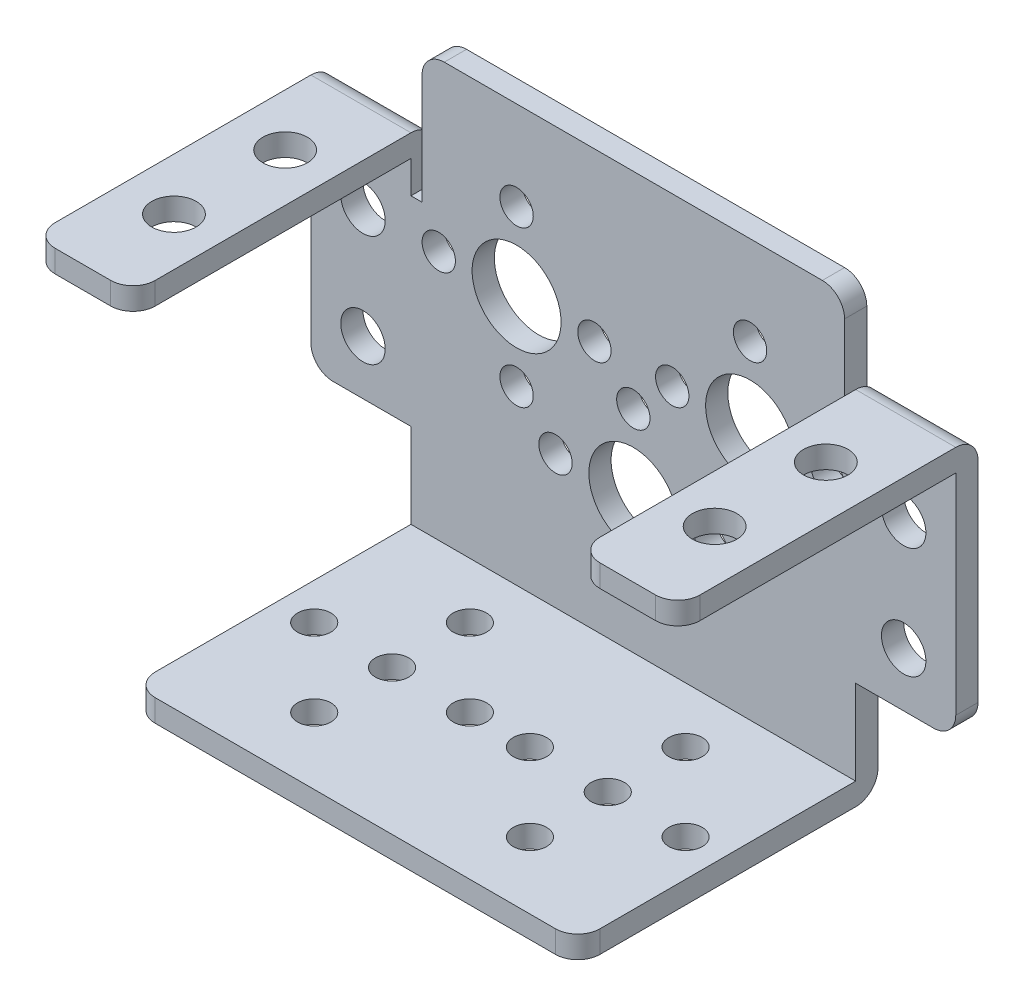
from build123d import *

# Parameters (mm, degrees)
SKETCH_1_R      = 4
SKETCH_1_R_2    = 1.5
SKETCH_1_R_3    = 2
EXTRUDE_1_DEPTH = 2
SKETCH_2_R      = 1.5
EXTRUDE_2_DEPTH = 2
FILLET_2_R      = 2
SKETCH_3_R      = 2
EXTRUDE_3_DEPTH = 2
FILLET_3_R      = 2
FILLET_4_R      = 2


with BuildPart() as part:
    # 草图1 → 凸台-拉伸1 (new body)
    with BuildSketch(Plane.XY):
        with BuildLine():
            Line((-17, 18.75), (17, 18.75))
            ThreePointArc((17, 18.75), (18.414213562, 18.164213562), (19, 16.75))
            Line((19, 16.75), (19, 6.838490702))
            Line((19, 6.838490702), (20, 6.838490702))
            Line((20, 6.838490702), (20, 9.75))
            Line((20, 9.75), (27, 9.75))
            Line((27, 9.75), (29, 9.75))
            Line((29, 9.75), (29, 7.75))
            Line((29, 7.75), (29, -9.12411328))
            ThreePointArc((29, -9.12411328), (28.414213562, -10.538326843), (27, -11.12411328))
            Line((27, -11.12411328), (20, -11.12411328))
            Line((20, -11.12411328), (20, -16.75))
            Line((20, -16.75), (20, -18.75))
            Line((20, -18.75), (18, -18.75))
            Line((18, -18.75), (-18, -18.75))
            Line((-18, -18.75), (-20, -18.75))
            Line((-20, -18.75), (-20, -16.75))
            Line((-20, -16.75), (-20, -11.12411328))
            Line((-20, -11.12411328), (-27, -11.12411328))
            ThreePointArc((-27, -11.12411328), (-28.414213562, -10.538326843), (-29, -9.12411328))
            Line((-29, -9.12411328), (-29, 7.75))
            Line((-29, 7.75), (-29, 9.75))
            Line((-29, 9.75), (-27, 9.75))
            Line((-27, 9.75), (-20, 9.75))
            Line((-20, 9.75), (-20, 6.838490702))
            Line((-20, 6.838490702), (-19, 6.838490702))
            Line((-19, 6.838490702), (-19, 16.75))
            ThreePointArc((-19, 16.75), (-18.414213562, 18.164213562), (-17, 18.75))
        make_face()
        with Locations((0, -6.75)):
            Circle(SKETCH_1_R, mode=Mode.SUBTRACT)
        with Locations((-10.5, 3.75)):
            Circle(SKETCH_1_R, mode=Mode.SUBTRACT)
        with Locations((-7, -6.75)):
            Circle(SKETCH_1_R_2, mode=Mode.SUBTRACT)
        with Locations((0, 0.25)):
            Circle(SKETCH_1_R_2, mode=Mode.SUBTRACT)
        with Locations((7, -6.75)):
            Circle(SKETCH_1_R_2, mode=Mode.SUBTRACT)
        with Locations((0, -13.75)):
            Circle(SKETCH_1_R_2, mode=Mode.SUBTRACT)
        with Locations((-17.5, 3.75)):
            Circle(SKETCH_1_R_2, mode=Mode.SUBTRACT)
        with Locations((10.5, -3.25)):
            Circle(SKETCH_1_R_2, mode=Mode.SUBTRACT)
        with Locations((-10.5, 10.75)):
            Circle(SKETCH_1_R_2, mode=Mode.SUBTRACT)
        with Locations((-3.5, 3.75)):
            Circle(SKETCH_1_R_2, mode=Mode.SUBTRACT)
        with Locations((-10.5, -3.25)):
            Circle(SKETCH_1_R_2, mode=Mode.SUBTRACT)
        with Locations((17.5, 3.75)):
            Circle(SKETCH_1_R_2, mode=Mode.SUBTRACT)
        with Locations((3.5, 3.75)):
            Circle(SKETCH_1_R_2, mode=Mode.SUBTRACT)
        with Locations((10.5, 3.75)):
            Circle(SKETCH_1_R, mode=Mode.SUBTRACT)
        with Locations((10.5, 10.75)):
            Circle(SKETCH_1_R_2, mode=Mode.SUBTRACT)
        with Locations((-24.315, -6.25)):
            Circle(SKETCH_1_R_3, mode=Mode.SUBTRACT)
        with Locations((-24.315, 3.75)):
            Circle(SKETCH_1_R_3, mode=Mode.SUBTRACT)
        with Locations((24.315, 3.75)):
            Circle(SKETCH_1_R_3, mode=Mode.SUBTRACT)
        with Locations((24.315, -6.25)):
            Circle(SKETCH_1_R_3, mode=Mode.SUBTRACT)
    extrude(amount=EXTRUDE_1_DEPTH)

    # 草图2 → 凸台-拉伸2 (add)
    with BuildSketch(Plane.XZ.offset(18.75)):
        with BuildLine():
            Line((-20, 0), (20, 0))
            Line((20, 0), (20, 25))
            ThreePointArc((20, 25), (19.414213562, 26.414213562), (18, 27))
            Line((18, 27), (-18, 27))
            ThreePointArc((-18, 27), (-19.414213562, 26.414213562), (-20, 25))
            Line((-20, 25), (-20, 0))
        make_face()
        with Locations((9.7, 14)):
            Circle(SKETCH_2_R, mode=Mode.SUBTRACT)
        with Locations((-9.7, 14)):
            Circle(SKETCH_2_R, mode=Mode.SUBTRACT)
        with Locations((-2.7, 14)):
            Circle(SKETCH_2_R, mode=Mode.SUBTRACT)
        with Locations((16.7, 14)):
            Circle(SKETCH_2_R, mode=Mode.SUBTRACT)
        with Locations((9.7, 7)):
            Circle(SKETCH_2_R, mode=Mode.SUBTRACT)
        with Locations((2.7, 14)):
            Circle(SKETCH_2_R, mode=Mode.SUBTRACT)
        with Locations((9.7, 21)):
            Circle(SKETCH_2_R, mode=Mode.SUBTRACT)
        with Locations((-9.7, 7)):
            Circle(SKETCH_2_R, mode=Mode.SUBTRACT)
        with Locations((-16.7, 14)):
            Circle(SKETCH_2_R, mode=Mode.SUBTRACT)
        with Locations((-9.7, 21)):
            Circle(SKETCH_2_R, mode=Mode.SUBTRACT)
    extrude(amount=EXTRUDE_2_DEPTH)

    # 圆角2
    fillet_2_edges = [part.edges().sort_by_distance(p)[0] for p in [
        (0, -20.75, 0),
    ]]
    fillet(fillet_2_edges, radius=FILLET_2_R)

    # 草图3 → 凸台-拉伸3 (add)
    with BuildSketch(Plane(origin=(0, 9.75, 0), x_dir=(1, 0, 0), z_dir=(0, 1, 0))):
        with BuildLine():
            Line((29, 0), (20, 0))
            Line((20, 0), (20, -25))
            ThreePointArc((20, -25), (20.585786438, -26.414213562), (22, -27))
            Line((22, -27), (27, -27))
            ThreePointArc((27, -27), (28.414213562, -26.414213562), (29, -25))
            Line((29, -25), (29, 0))
        make_face()
        with Locations((24.315, -9)):
            Circle(SKETCH_3_R, mode=Mode.SUBTRACT)
        with Locations((24.315, -19)):
            Circle(SKETCH_3_R, mode=Mode.SUBTRACT)
        with BuildLine():
            Line((-29, 0), (-20, 0))
            Line((-20, 0), (-20, -25))
            ThreePointArc((-20, -25), (-20.585786438, -26.414213562), (-22, -27))
            Line((-22, -27), (-27, -27))
            ThreePointArc((-27, -27), (-28.414213562, -26.414213562), (-29, -25))
            Line((-29, -25), (-29, 0))
        make_face()
        with Locations((-24.315, -19)):
            Circle(SKETCH_3_R, mode=Mode.SUBTRACT)
        with Locations((-24.315, -9)):
            Circle(SKETCH_3_R, mode=Mode.SUBTRACT)
    extrude(amount=EXTRUDE_3_DEPTH)

    # 圆角3
    fillet_3_edges = [part.edges().sort_by_distance(p)[0] for p in [
        (24.5, 11.75, 0),
    ]]
    fillet(fillet_3_edges, radius=FILLET_3_R)

    # 圆角4
    fillet_4_edges = [part.edges().sort_by_distance(p)[0] for p in [
        (-24.5, 11.75, 0),
    ]]
    fillet(fillet_4_edges, radius=FILLET_4_R)


solid = part.part
